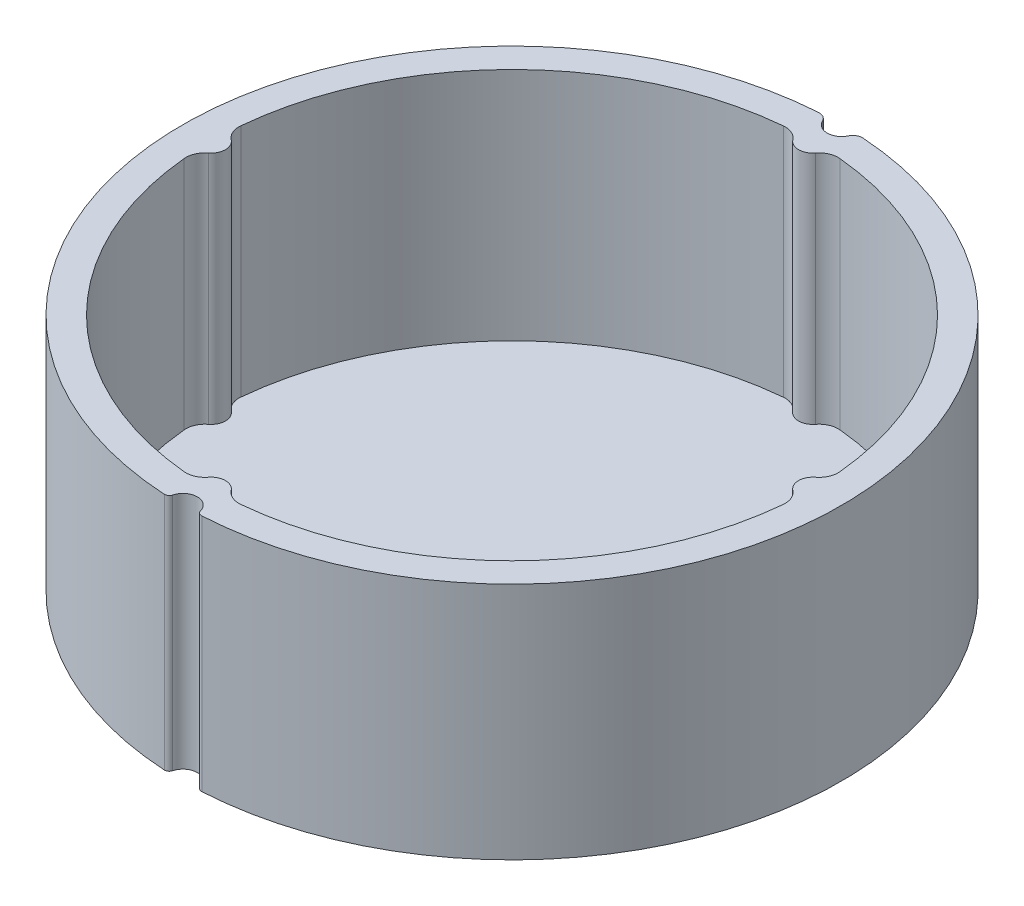
from build123d import *

# Parameters (mm, degrees)
BOSS_EXTRUDE1_DEPTH = 25
CUT_EXTRUDE2_DEPTH  = 55.786493398
BOSS_EXTRUDE2_DEPTH = 0.4


with BuildPart() as part:
    # Sketch1 → Boss-Extrude1 (new body)
    with BuildSketch(Plane(origin=(0, 0, 0), x_dir=(1, 0, 0), z_dir=(0, 1, 0))):
        with BuildLine():
            ThreePointArc((1.451818925, -34.068556857), (1.641248992, -34.346908706), (1.964225605, -34.442038138))
            ThreePointArc((1.964225605, -34.442038138), (26.591847487, -21.978073076), (34.198225299, 4.555174015))
            ThreePointArc((34.198225299, 4.555174015), (23.590291339, 25.176355888), (2.324135821, 34.423627607))
            ThreePointArc((2.324135821, 34.423627607), (1.751838249, 34.289058819), (1.354061739, 33.856153382))
            ThreePointArc((1.354061739, 33.856153382), (0, 33.001534515), (-1.354061739, 33.856153382))
            ThreePointArc((-1.354061739, 33.856153382), (-1.751838249, 34.289058819), (-2.324135821, 34.423627607))
            ThreePointArc((-2.324135821, 34.423627607), (-23.590291339, 25.176355888), (-34.198225299, 4.555174015))
            ThreePointArc((-34.198225299, 4.555174015), (-26.591847487, -21.978073076), (-1.964225605, -34.442038138))
            ThreePointArc((-1.964225605, -34.442038138), (-1.641248992, -34.346908706), (-1.451818925, -34.068556857))
            ThreePointArc((-1.451818925, -34.068556857), (0, -32.945679925), (1.451818925, -34.068556857))
        make_face()
        with BuildLine():
            Line((-2.417, 3.787737139), (0, 3.787737139))
            Line((0, 3.787737139), (2.417, 3.787737139))
            ThreePointArc((2.417, 3.787737139), (0, -4.489512172), (-2.417, 3.787737139))
        make_face(mode=Mode.SUBTRACT)
    extrude(amount=BOSS_EXTRUDE1_DEPTH)

    # Sketch2 → Cut-Extrude2 (cut, through all)
    with BuildSketch(Plane(origin=(0, 0, 0), x_dir=(1, 0, 0), z_dir=(0, 1, 0))):
        with BuildLine():
            ThreePointArc((-31.360169492, -2.964754537), (-22.273863607, -22.273863607), (-2.964754537, -31.360169492))
            ThreePointArc((-2.964754537, -31.360169492), (-1.977522645, -31.202516837), (-1.189935494, -30.586734694))
            ThreePointArc((-1.189935494, -30.586734694), (0, -30), (1.189935494, -30.586734694))
            ThreePointArc((1.189935494, -30.586734694), (1.977522645, -31.202516837), (2.964754537, -31.360169492))
            ThreePointArc((2.964754537, -31.360169492), (22.273863607, -22.273863607), (31.360169492, -2.964754537))
            ThreePointArc((31.360169492, -2.964754537), (31.202516837, -1.977522645), (30.586734694, -1.189935494))
            ThreePointArc((30.586734694, -1.189935494), (30, 0), (30.586734694, 1.189935494))
            ThreePointArc((30.586734694, 1.189935494), (31.202516837, 1.977522645), (31.360169492, 2.964754537))
            ThreePointArc((31.360169492, 2.964754537), (22.273863607, 22.273863607), (2.964754537, 31.360169492))
            ThreePointArc((2.964754537, 31.360169492), (1.977522645, 31.202516837), (1.189935494, 30.586734694))
            ThreePointArc((1.189935494, 30.586734694), (0, 30), (-1.189935494, 30.586734694))
            ThreePointArc((-1.189935494, 30.586734694), (-1.977522645, 31.202516837), (-2.964754537, 31.360169492))
            ThreePointArc((-2.964754537, 31.360169492), (-22.273863607, 22.273863607), (-31.360169492, 2.964754537))
            ThreePointArc((-31.360169492, 2.964754537), (-31.202516837, 1.977522645), (-30.586734694, 1.189935494))
            ThreePointArc((-30.586734694, 1.189935494), (-30, 0), (-30.586734694, -1.189935494))
            ThreePointArc((-30.586734694, -1.189935494), (-31.202516837, -1.977522645), (-31.360169492, -2.964754537))
        make_face()
    extrude(amount=CUT_EXTRUDE2_DEPTH, mode=Mode.SUBTRACT)

    # Sketch2_2 → Boss-Extrude2 (add)
    with BuildSketch(Plane(origin=(0, 0, 0), x_dir=(1, 0, 0), z_dir=(0, 1, 0))):
        with BuildLine():
            ThreePointArc((-31.360169492, -2.964754537), (-22.273863607, -22.273863607), (-2.964754537, -31.360169492))
            ThreePointArc((-2.964754537, -31.360169492), (-1.977522645, -31.202516837), (-1.189935494, -30.586734694))
            ThreePointArc((-1.189935494, -30.586734694), (0, -30), (1.189935494, -30.586734694))
            ThreePointArc((1.189935494, -30.586734694), (1.977522645, -31.202516837), (2.964754537, -31.360169492))
            ThreePointArc((2.964754537, -31.360169492), (22.273863607, -22.273863607), (31.360169492, -2.964754537))
            ThreePointArc((31.360169492, -2.964754537), (31.202516837, -1.977522645), (30.586734694, -1.189935494))
            ThreePointArc((30.586734694, -1.189935494), (30, 0), (30.586734694, 1.189935494))
            ThreePointArc((30.586734694, 1.189935494), (31.202516837, 1.977522645), (31.360169492, 2.964754537))
            ThreePointArc((31.360169492, 2.964754537), (22.273863607, 22.273863607), (2.964754537, 31.360169492))
            ThreePointArc((2.964754537, 31.360169492), (1.977522645, 31.202516837), (1.189935494, 30.586734694))
            ThreePointArc((1.189935494, 30.586734694), (0, 30), (-1.189935494, 30.586734694))
            ThreePointArc((-1.189935494, 30.586734694), (-1.977522645, 31.202516837), (-2.964754537, 31.360169492))
            ThreePointArc((-2.964754537, 31.360169492), (-22.273863607, 22.273863607), (-31.360169492, 2.964754537))
            ThreePointArc((-31.360169492, 2.964754537), (-31.202516837, 1.977522645), (-30.586734694, 1.189935494))
            ThreePointArc((-30.586734694, 1.189935494), (-30, 0), (-30.586734694, -1.189935494))
            ThreePointArc((-30.586734694, -1.189935494), (-31.202516837, -1.977522645), (-31.360169492, -2.964754537))
        make_face()
    extrude(amount=BOSS_EXTRUDE2_DEPTH)


solid = part.part
